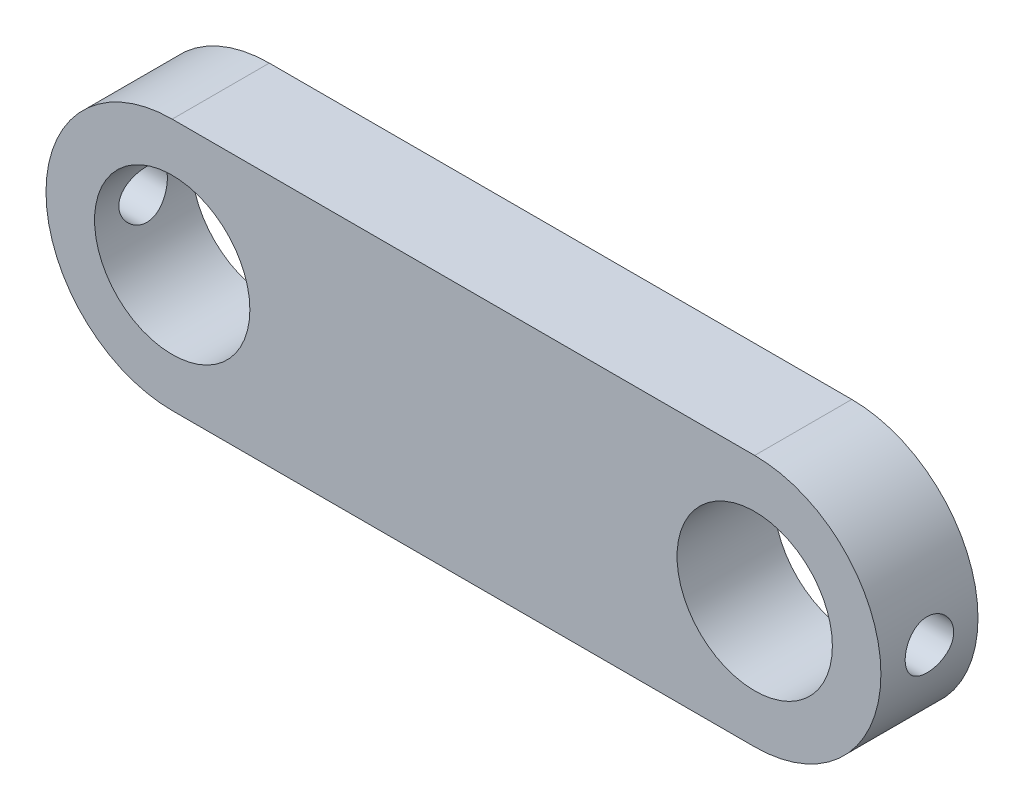
from build123d import *

# Parameters (mm, degrees)
SKETCH1_R           = 4
BOSS_EXTRUDE1_DEPTH = 5
CUT_EXTRUDE1_DEPTH  = 5


with BuildPart() as part:
    # Sketch1 → Boss-Extrude1 (new body)
    with BuildSketch(Plane.XY):
        with BuildLine():
            Line((-15, 6.5), (15, 6.5))
            ThreePointArc((15, 6.5), (21.5, 0), (15, -6.5))
            Line((15, -6.5), (-15, -6.5))
            ThreePointArc((-15, -6.5), (-21.5, 0), (-15, 6.5))
        make_face()
        with Locations((-15, 0)):
            Circle(SKETCH1_R, mode=Mode.SUBTRACT)
        with Locations((15, 0)):
            Circle(SKETCH1_R, mode=Mode.SUBTRACT)
    extrude(amount=BOSS_EXTRUDE1_DEPTH)

    # Sketch2 → Cut-Extrude1 (cut)
    with BuildSketch(Plane(origin=(21.5, 0, 0), x_dir=(0, 0, -1), z_dir=(1, 0, 0))):
        with BuildLine():
            ThreePointArc((-3.75, 0), (-2.5, -1.25), (-1.25, 0))
            Line((-1.25, 0), (-3.75, 0))
        make_face()
        with BuildLine():
            Line((-3.75, 0), (-1.25, 0))
            ThreePointArc((-1.25, 0), (-2.5, 1.25), (-3.75, 0))
        make_face()
    cut_extrude1 = extrude(amount=-CUT_EXTRUDE1_DEPTH, mode=Mode.SUBTRACT)

    # Mirror1: Cut-Extrude1 across plane
    add(cut_extrude1.mirror(Plane(origin=(0, 0, 0), x_dir=(0, 0, 1), z_dir=(1, 0, 0))), mode=Mode.SUBTRACT)


solid = part.part
